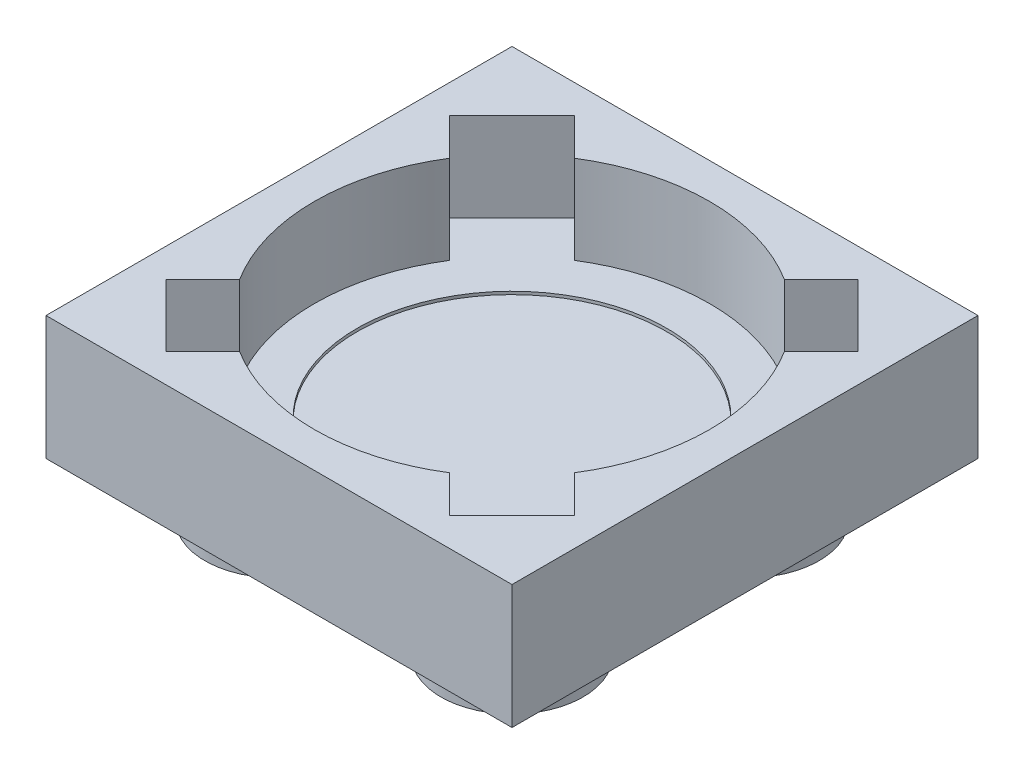
from build123d import *

# Parameters (mm, degrees)
SKETCH2_W            = 15.8
SKETCH2_H            = 15.8
BOSS_EXTRUDE2_DEPTH  = 4.2
SKETCH4_W            = 13.4
SKETCH4_H            = 13.4
CUT_EXTRUDE1_DEPTH   = 3
SKETCH6_R            = 2.41
BOSS_EXTRUDE4_DEPTH  = 1.8
LPATTERN1_COUNT      = 2
LPATTERN1_PITCH      = 8
LPATTERN1_COUNT_DIR2 = 2
LPATTERN1_PITCH_DIR2 = 8
SKETCH8_R            = 5.25
CUT_EXTRUDE2_DEPTH   = 0.1
BOSS_EXTRUDE9_DEPTH  = 3
CUT_EXTRUDE3_DEPTH   = 3
CIRPATTERN3_COUNT    = 4


with BuildPart() as part:
    # Sketch2 → Boss-Extrude2 (new body)
    with BuildSketch(Plane(origin=(0, 0, 0), x_dir=(1, 0, 0), z_dir=(0, 1, 0))):
        with Locations((7.9, 7.9)):
            Rectangle(SKETCH2_W, SKETCH2_H)
    extrude(amount=-BOSS_EXTRUDE2_DEPTH)

    # Sketch4 → Cut-Extrude1 (cut)
    with BuildSketch(Plane(origin=(0, 0, 0), x_dir=(1, 0, 0), z_dir=(0, 1, 0))):
        with Locations((7.9, 7.9)):
            Rectangle(SKETCH4_W, SKETCH4_H)
    extrude(amount=-CUT_EXTRUDE1_DEPTH, mode=Mode.SUBTRACT)

    # Sketch6 → Boss-Extrude4 (add)
    with BuildSketch(Plane(origin=(0, -4.2, 0), x_dir=(-1, 0, 0), z_dir=(0, -1, 0))):
        with Locations((-11.9, 11.9)):
            Circle(SKETCH6_R)
    boss_extrude4 = extrude(amount=BOSS_EXTRUDE4_DEPTH)

    # LPattern1: Boss-Extrude4 2 × 2
    with Locations(*[(-j * LPATTERN1_PITCH_DIR2, 0, i * LPATTERN1_PITCH) for i in range(LPATTERN1_COUNT) for j in range(LPATTERN1_COUNT_DIR2) if (i, j) != (0, 0)]):
        add(boss_extrude4)

    # Sketch8 → Cut-Extrude2 (cut)
    with BuildSketch(Plane(origin=(0, -3, 0), x_dir=(1, 0, 0), z_dir=(0, 1, 0))):
        with Locations((7.9, 7.9)):
            Circle(SKETCH8_R)
    extrude(amount=-CUT_EXTRUDE2_DEPTH, mode=Mode.SUBTRACT)

    # Sketch11 → Boss-Extrude9 (add)
    with BuildSketch(Plane(origin=(0, -3, 0), x_dir=(1, 0, 0), z_dir=(0, 1, 0))):
        with BuildLine():
            Line((7.899999971, 14.6), (1.2, 14.6))
            Line((1.2, 14.6), (1.2, 7.9))
            ThreePointArc((1.2, 7.9), (3.162384556, 12.637615424), (7.899999971, 14.6))
        make_face()
        with BuildLine():
            Line((14.6, 14.6), (7.899999971, 14.6))
            ThreePointArc((7.899999971, 14.6), (12.637615424, 12.637615444), (14.6, 7.9))
            Line((14.6, 7.9), (14.6, 14.6))
        make_face()
        with BuildLine():
            ThreePointArc((7.900000011, 1.2), (3.16238457, 3.162384562), (1.2, 7.9))
            Line((1.2, 7.9), (1.2, 1.2))
            Line((1.2, 1.2), (7.900000011, 1.2))
        make_face()
        with BuildLine():
            Line((14.6, 1.2), (14.6, 7.9))
            ThreePointArc((14.6, 7.9), (12.637615438, 3.16238457), (7.900000011, 1.2))
            Line((7.900000011, 1.2), (14.6, 1.2))
        make_face()
    extrude(amount=BOSS_EXTRUDE9_DEPTH)

    # Sketch12 → Cut-Extrude3 (cut)
    with BuildSketch(Plane(origin=(0, 0, 0), x_dir=(1, 0, 0), z_dir=(0, 1, 0))):
        Polygon((3.162384566, 12.637615434), (2.031013716, 13.768986284), (0.970353544, 12.708326112), (2.101724394, 11.576955262), align=None)
        with BuildLine():
            ThreePointArc((2.221981276, 11.45669838), (2.658816927, 12.073727351), (3.162384566, 12.637615434))
            Line((3.162384566, 12.637615434), (2.101724394, 11.576955262))
            Line((2.101724394, 11.576955262), (2.221981276, 11.45669838))
        make_face()
        with BuildLine():
            Line((4.223044738, 13.698275606), (3.162384566, 12.637615434))
            ThreePointArc((3.162384566, 12.637615434), (3.726272649, 13.141183073), (4.34330162, 13.578018724))
            Line((4.34330162, 13.578018724), (4.223044738, 13.698275606))
        make_face()
        Polygon((3.091673888, 14.829646456), (2.031013716, 13.768986284), (3.162384566, 12.637615434), (4.223044738, 13.698275606), align=None)
        with BuildLine():
            ThreePointArc((4.34330162, 13.578018724), (3.726272649, 13.141183073), (3.162384566, 12.637615434))
            ThreePointArc((3.162384566, 12.637615434), (2.658816927, 12.073727351), (2.221981276, 11.45669838))
            Line((2.221981276, 11.45669838), (2.423581348, 11.255098309))
            Line((2.423581348, 11.255098309), (4.544901691, 13.376418652))
            Line((4.544901691, 13.376418652), (4.34330162, 13.578018724))
        make_face()
        with BuildLine():
            ThreePointArc((14.6, 7.9), (11.145005458, 13.761735202), (4.34330162, 13.578018724))
            Line((4.34330162, 13.578018724), (4.544901691, 13.376418652))
            Line((4.544901691, 13.376418652), (2.423581348, 11.255098309))
            Line((2.423581348, 11.255098309), (2.221981276, 11.45669838))
            ThreePointArc((2.221981276, 11.45669838), (6.049692654, 1.460561925), (14.6, 7.9))
        make_face()
    cut_extrude3 = extrude(amount=-CUT_EXTRUDE3_DEPTH, mode=Mode.SUBTRACT)

    # CirPattern3: Cut-Extrude3 ×4 about axis
    cirpattern3_axis = Axis((7.9, 0, -7.9), (0, 1, 0))
    for i in range(1, CIRPATTERN3_COUNT):
        add(cut_extrude3.rotate(cirpattern3_axis, i * 360 / CIRPATTERN3_COUNT), mode=Mode.SUBTRACT)


solid = part.part
